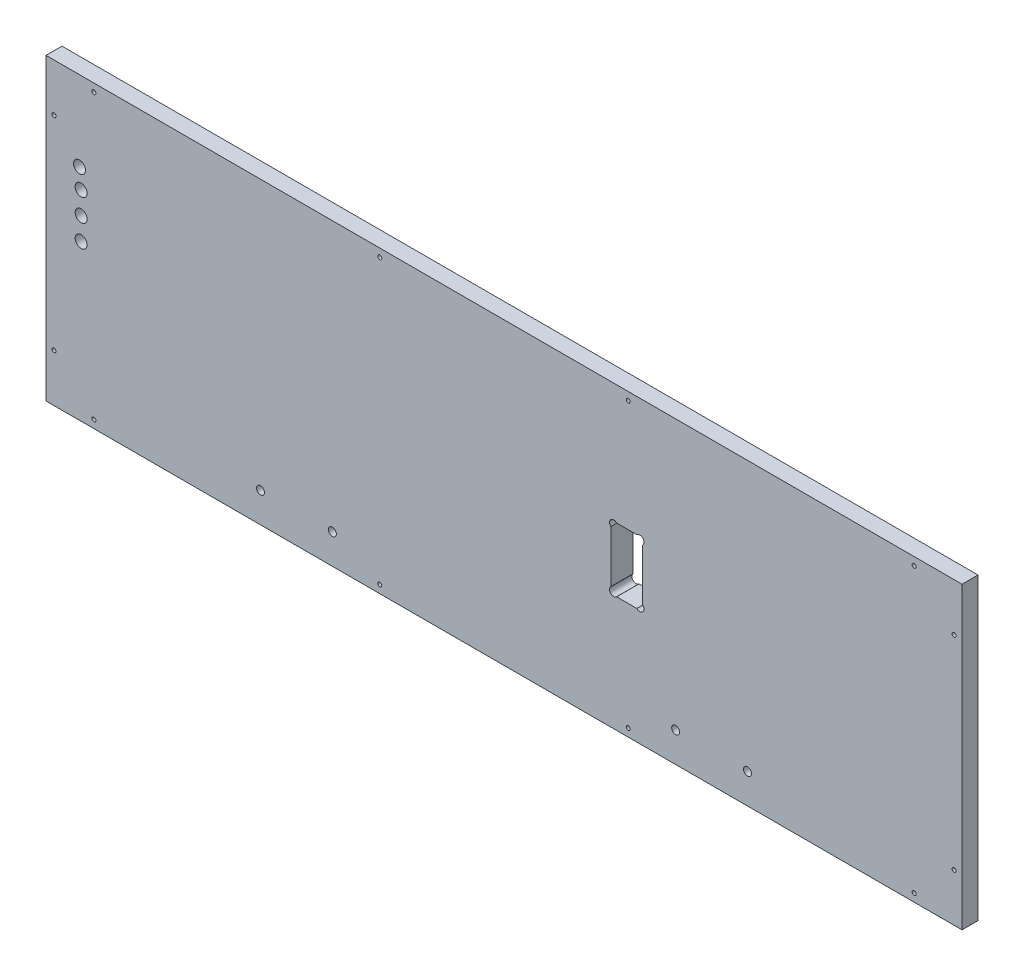
from build123d import *

# Parameters (mm, degrees)
BACKOUTLINE_W               = 728.6625
BACKOUTLINE_H               = 238.125
BACKOUTLINE_THICKNESS_DEPTH = 17.78
BCAKHOLES_R                 = 1.5875
BCAKHOLES_R_2               = 3.175
BCAKHOLES_W                 = 25.4
BCAKHOLES_H                 = 50.8
CUT_EXTRUDE1_DEPTH          = 17.78
SKETCH6_R                   = 3.302
CUT_EXTRUDE4_DEPTH          = 17.78
BACKPOWERBOXLIP_W           = 169.8625
BACKPOWERBOXLIP_H           = 9.525
CUT_EXTRUDE2_DEPTH          = 3.175
CUT_EXTRUDE3_DEPTH          = 5.08
SKETCH7_R                   = 3.302
CUT_EXTRUDE5_DEPTH          = 5.08
BACKAMPACCESSHOLES_R        = 4.7625
CUT_EXTRUDE6_DEPTH          = 17.78


with BuildPart() as part:
    # BackOutline → BackOutline_Thickness (new body)
    with BuildSketch(Plane.XY):
        with Locations((-5376.06875, 779.4625)):
            Rectangle(BACKOUTLINE_W, BACKOUTLINE_H)
    extrude(amount=-BACKOUTLINE_THICKNESS_DEPTH)

    # BcakHoles → Cut-Extrude1 (cut)
    with BuildSketch(Plane.XY):
        with Locations((-5702.3, 892.175)):
            Circle(BCAKHOLES_R)
        with Locations((-5734.05, 860.425)):
            Circle(BCAKHOLES_R)
        with Locations((-5734.05, 698.5)):
            Circle(BCAKHOLES_R)
        with Locations((-5702.3, 666.75)):
            Circle(BCAKHOLES_R)
        with Locations((-5569.74375, 684.2125)):
            Circle(BCAKHOLES_R_2)
        with Locations((-5512.59375, 684.2125)):
            Circle(BCAKHOLES_R_2)
        with Locations((-5474.890625, 666.75)):
            Circle(BCAKHOLES_R)
        with Locations((-5277.246875, 666.75)):
            Circle(BCAKHOLES_R)
        with Locations((-5239.54375, 684.2125)):
            Circle(BCAKHOLES_R_2)
        with Locations((-5182.39375, 684.2125)):
            Circle(BCAKHOLES_R_2)
        with Locations((-5049.8375, 666.75)):
            Circle(BCAKHOLES_R)
        with Locations((-5018.0875, 698.5)):
            Circle(BCAKHOLES_R)
        with Locations((-5018.0875, 860.425)):
            Circle(BCAKHOLES_R)
        with Locations((-5049.8375, 892.175)):
            Circle(BCAKHOLES_R)
        with Locations((-5277.246875, 892.175)):
            Circle(BCAKHOLES_R)
        with Locations((-5474.890625, 892.175)):
            Circle(BCAKHOLES_R)
        with Locations((-5278.4375, 777.875)):
            Rectangle(BCAKHOLES_W, BCAKHOLES_H)
    extrude(amount=-CUT_EXTRUDE1_DEPTH, mode=Mode.SUBTRACT)

    # Sketch6 → Cut-Extrude4 (cut)
    with BuildSketch(Plane.XY):
        with Locations((-5288.802633409, 800.940133409)):
            Circle(SKETCH6_R)
        with Locations((-5268.072366591, 800.940133409)):
            Circle(SKETCH6_R)
        with Locations((-5288.802633409, 754.809866591)):
            Circle(SKETCH6_R)
        with Locations((-5268.072366591, 754.809866591)):
            Circle(SKETCH6_R)
    extrude(amount=-CUT_EXTRUDE4_DEPTH, mode=Mode.SUBTRACT)

    # BackPowerBoxLip → Cut-Extrude2 (cut)
    with BuildSketch(Plane.XZ.offset(-660.4)):
        with Locations((-5376.06875, -13.0175)):
            Rectangle(BACKPOWERBOXLIP_W, BACKPOWERBOXLIP_H)
    extrude(amount=-CUT_EXTRUDE2_DEPTH, mode=Mode.SUBTRACT)

    # BackLedge → Cut-Extrude3 (cut)
    with BuildSketch(Plane(origin=(0, 0, -17.78), x_dir=(-1, 0, 0), z_dir=(0, 0, -1))):
        Polygon((5011.7375, 660.4), (5113.3375, 660.4), (5113.3375, 673.1), (5024.4375, 673.1), (5024.4375, 885.825), (5727.7, 885.825), (5727.7, 673.1), (5638.8, 673.1), (5638.8, 660.4), (5740.4, 660.4), (5740.4, 898.525), (5011.7375, 898.525), align=None)
    extrude(amount=-CUT_EXTRUDE3_DEPTH, mode=Mode.SUBTRACT)

    # Sketch7 → Cut-Extrude5 (cut)
    with BuildSketch(Plane(origin=(0, 0, -17.78), x_dir=(-1, 0, 0), z_dir=(0, 0, -1))):
        with Locations((5641.525003649, 671.235178531)):
            Circle(SKETCH7_R)
        with Locations((5110.612496351, 671.235178531)):
            Circle(SKETCH7_R)
    extrude(amount=-CUT_EXTRUDE5_DEPTH, mode=Mode.SUBTRACT)

    # BackAmpAccessHoles → Cut-Extrude6 (cut)
    with BuildSketch(Plane(origin=(0, 0, -17.78), x_dir=(-1, 0, 0), z_dir=(0, 0, -1))):
        with Locations((5713.73, 835.025)):
            Circle(BACKAMPACCESSHOLES_R)
        with Locations((5712.46, 819.785)):
            Circle(BACKAMPACCESSHOLES_R)
        with Locations((5712.46, 802.005)):
            Circle(BACKAMPACCESSHOLES_R)
        with Locations((5712.46, 784.225)):
            Circle(BACKAMPACCESSHOLES_R)
    extrude(amount=-CUT_EXTRUDE6_DEPTH, mode=Mode.SUBTRACT)


solid = part.part
